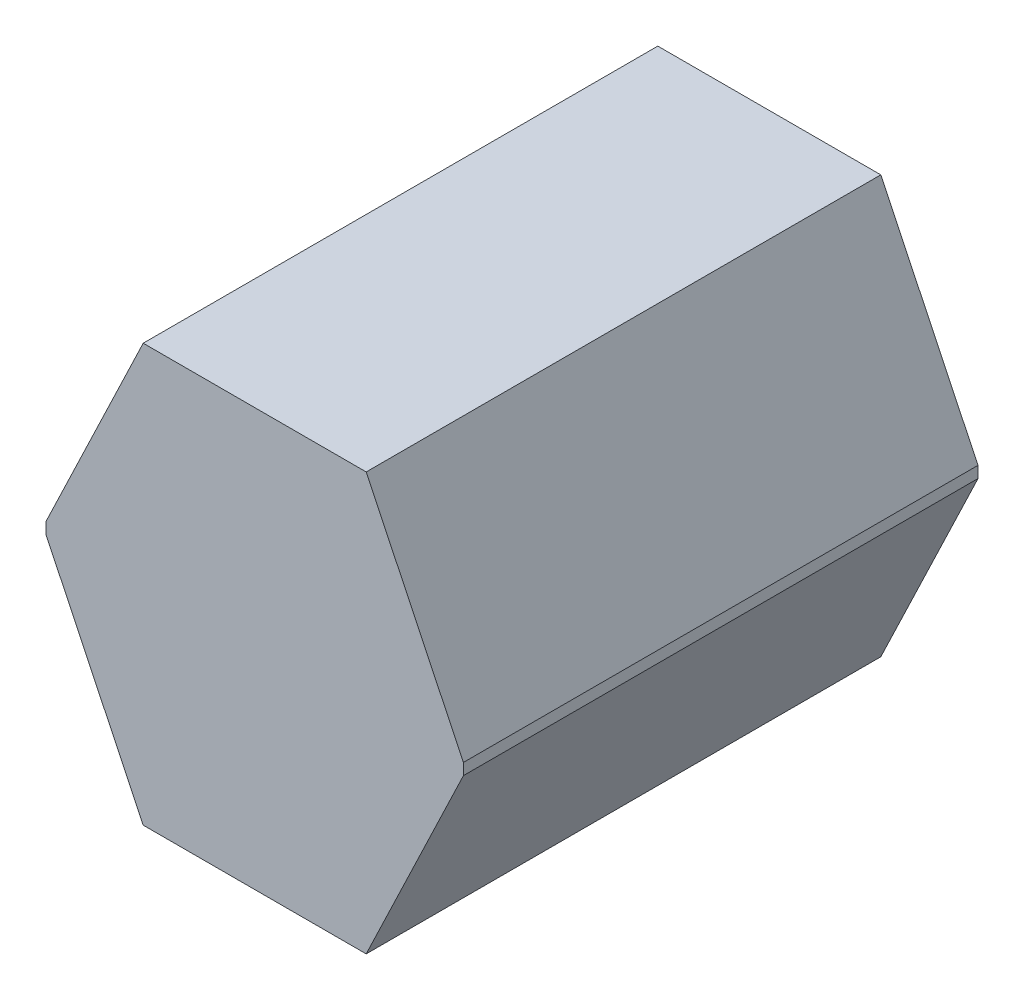
from build123d import *

# Parameters (mm, degrees)
AUFSATZ_LINEAR_AUSTRAGEN1_DEPTH = 450


with BuildPart() as part:
    # Skizze1 → Aufsatz-Linear austragen1 (new body)
    with BuildSketch(Plane.XY):
        Polygon((97.5, 182.5), (-97.5, 182.5), (-182.5, 5), (-182.5, -5), (-97.5, -182.5), (97.5, -182.5), (182.5, -5), (182.5, 5), align=None)
    extrude(amount=AUFSATZ_LINEAR_AUSTRAGEN1_DEPTH)


solid = part.part
